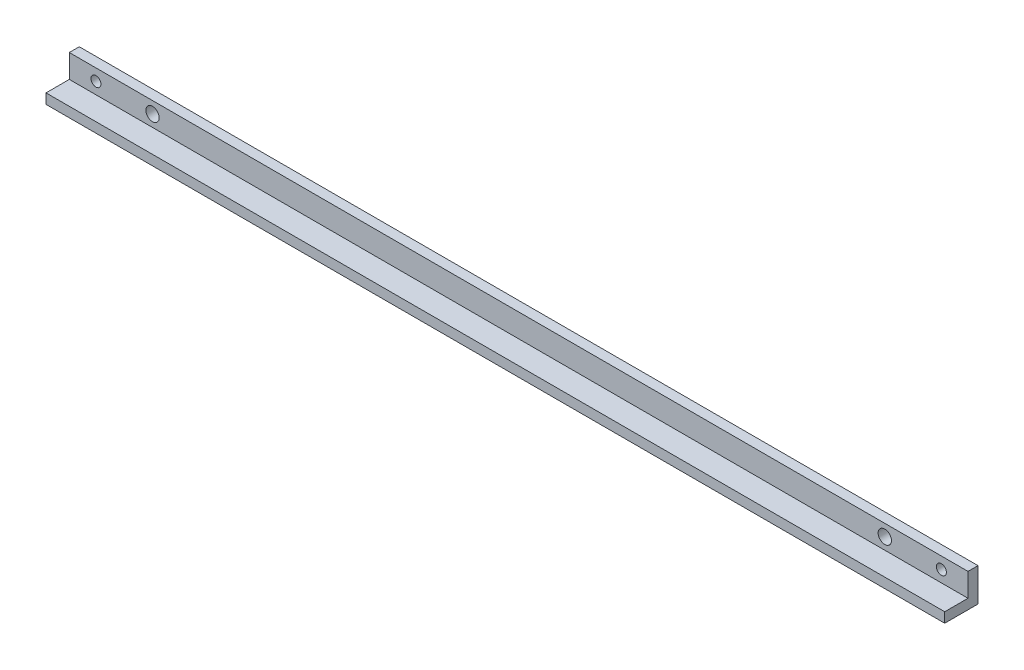
from build123d import *

# Parameters (mm, degrees)
EXTRUDE_1_DEPTH     = 270
SKETCH_2_R          = 2
CUT_EXTRUDE_1_DEPTH = 4
SKETCH_5_R          = 1.5
CUT_EXTRUDE_2_DEPTH = 4


with BuildPart() as part:
    # Эскиз1 → Бобышка-Вытянуть1 (new body)
    with BuildSketch(Plane(origin=(0, 0, 0), x_dir=(0, 0, -1), z_dir=(1, 0, 0))):
        Polygon((0, 0), (-10, 0), (-10, 3), (-3, 3), (-3, 10), (0, 10), align=None)
    extrude(amount=EXTRUDE_1_DEPTH)

    # Эскиз2 → Вырез-Вытянуть1 (cut, through all)
    with BuildSketch(Plane.XY.offset(3)):
        with Locations((25, 6.5)):
            Circle(SKETCH_2_R)
        with Locations((245, 6.5)):
            Circle(SKETCH_2_R)
    extrude(amount=-CUT_EXTRUDE_1_DEPTH, mode=Mode.SUBTRACT)

    # Эскиз5 → Вырез-Вытянуть2 (cut, through all)
    with BuildSketch(Plane.XY.offset(3)):
        with Locations((8, 6.5)):
            Circle(SKETCH_5_R)
        with Locations((262, 6.5)):
            Circle(SKETCH_5_R)
    extrude(amount=-CUT_EXTRUDE_2_DEPTH, mode=Mode.SUBTRACT)


solid = part.part
